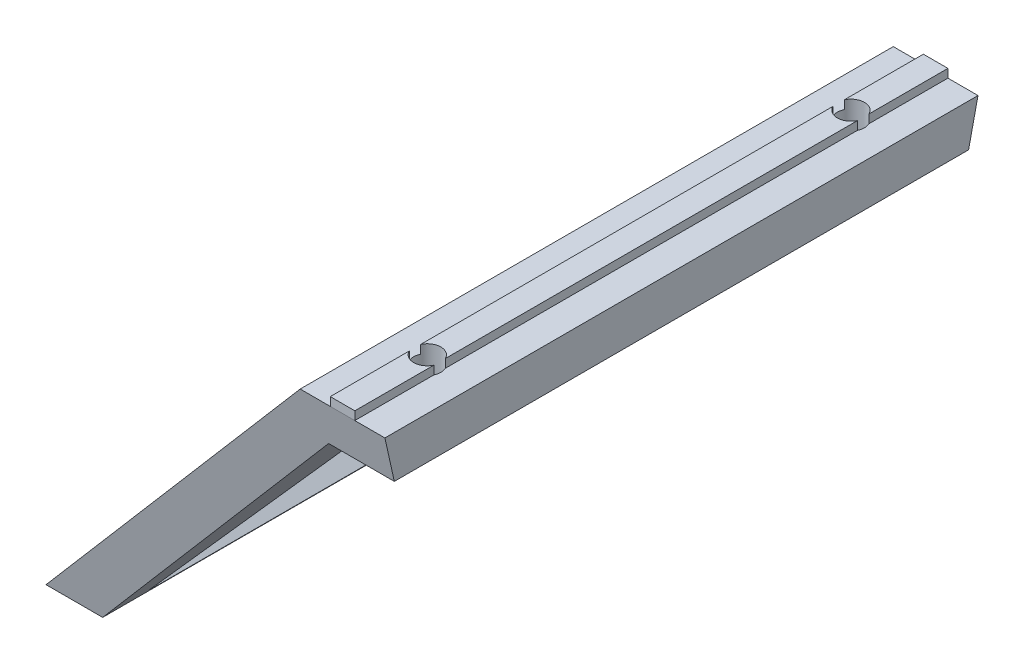
from build123d import *

# Parameters (mm, degrees)
MAIN_DEPTH                   = 35
SIDECUT_DEPTH                = 51
SIDECUT_DEPTH_BACK           = 1
SKETCH5_W                    = 40
SKETCH5_H                    = 50.207972894
CENTRALCUT_DEPTH             = 38.370465934
SKETCH3_R                    = 1.6
MAKERBEAMFIXHOLES_DEPTH      = 1
MAKERBEAMFIXHOLES_DEPTH_BACK = 47
ROLLERSUPPORTHOLES_DEPTH     = 22.5
LPATTERN1_COUNT              = 5
LPATTERN1_PITCH              = 10


with BuildPart() as part:
    # Sketch1 → Main (new body, symmetric)
    with BuildSketch(Plane.XY):
        Polygon((50, 45), (50, 40), (42.245330322, 40), (6.689774766, 0), (0, 0), (40, 45), (43.55, 45), (43.55, 46), (46.45, 46), (46.45, 45), align=None)
    extrude(amount=MAIN_DEPTH, both=True)

    # Sketch2 → SideCut (cut, two sides)
    with BuildSketch(Plane(origin=(0, 12.071067812, 0), x_dir=(0, 0, 1), z_dir=(1, 0, 0))) as sidecut_sk:
        Polygon((-35, -32.928932188), (-25, 12.071067812), (-35, 12.071067812), align=None)
        Polygon((35, -32.928932188), (35, 12.071067812), (25, 12.071067812), align=None)
    extrude(amount=SIDECUT_DEPTH, mode=Mode.SUBTRACT)
    extrude(sidecut_sk.sketch, amount=-SIDECUT_DEPTH_BACK, mode=Mode.SUBTRACT)

    # Sketch5 → CentralCut (cut, through all)
    with BuildSketch(Plane(origin=(0, 0, 0), x_dir=(0, 0, 1), z_dir=(-0.747409319, 0.664363839, 0))):
        with Locations((0, 30.103986447)):
            Rectangle(SKETCH5_W, SKETCH5_H)
    extrude(amount=-CENTRALCUT_DEPTH, mode=Mode.SUBTRACT)

    # Sketch3 → MakerBeamFixHoles (cut, two sides)
    with BuildSketch(Plane(origin=(0, 46, 0), x_dir=(1, 0, 0), z_dir=(0, 1, 0))) as makerbeamfixholes_sk:
        with Locations((45, 25)):
            Circle(SKETCH3_R)
        with Locations((45, -25)):
            Circle(SKETCH3_R)
    extrude(amount=MAKERBEAMFIXHOLES_DEPTH, mode=Mode.SUBTRACT)
    extrude(makerbeamfixholes_sk.sketch, amount=-MAKERBEAMFIXHOLES_DEPTH_BACK, mode=Mode.SUBTRACT)

    # Sketch4 → RollerSupportHoles (cut, symmetric)
    with BuildSketch(Plane.XY):
        with BuildLine():
            Line((34.685089289, 39.020725451), (32.691997773, 36.778497494))
            Line((32.691997773, 36.778497494), (33.813111751, 35.781951736))
            ThreePointArc((33.813111751, 35.781951736), (35.930771487, 35.906519956), (35.806203267, 38.024179692))
            Line((35.806203267, 38.024179692), (34.685089289, 39.020725451))
        make_face()
    rollersupportholes = extrude(amount=ROLLERSUPPORTHOLES_DEPTH, both=True, mode=Mode.SUBTRACT)

    # LPattern1: RollerSupportHoles ×5
    with Locations(*[Vector(-0.664363839, -0.747409319, 0) * (i * LPATTERN1_PITCH) for i in range(1, LPATTERN1_COUNT)]):
        add(rollersupportholes, mode=Mode.SUBTRACT)


solid = part.part
